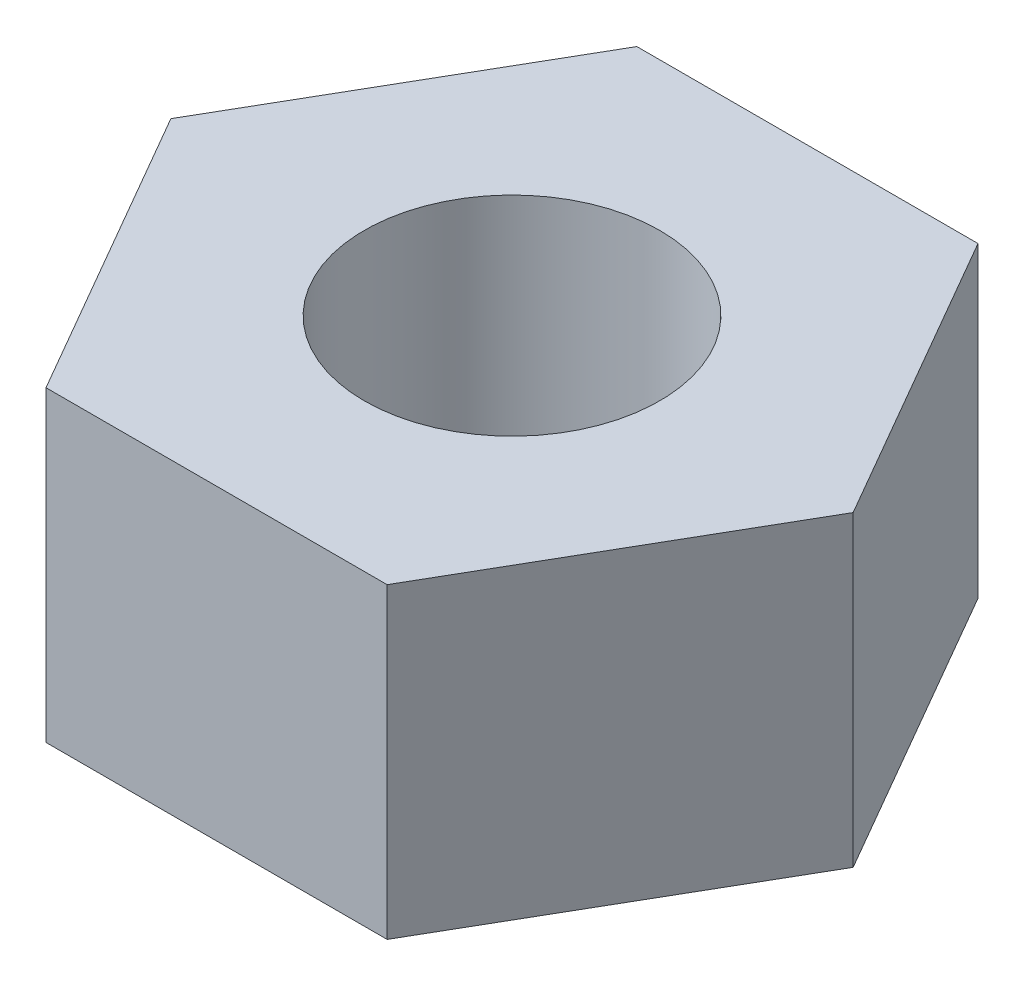
from build123d import *

# Parameters (mm, degrees)
ESQUISSE1_R        = 2.5
BOSS_EXTRU_1_DEPTH = 5.2


with BuildPart() as part:
    # Esquisse1 → Boss.-Extru.1 (new body)
    with BuildSketch(Plane(origin=(0, 0, 0), x_dir=(1, 0, 0), z_dir=(0, 1, 0))):
        Polygon((-2.886751346, 5), (-5.773502692, 0), (-2.886751346, -5), (2.886751346, -5), (5.773502692, 0), (2.886751346, 5), align=None)
        Circle(ESQUISSE1_R, mode=Mode.SUBTRACT)
    extrude(amount=BOSS_EXTRU_1_DEPTH)


solid = part.part
